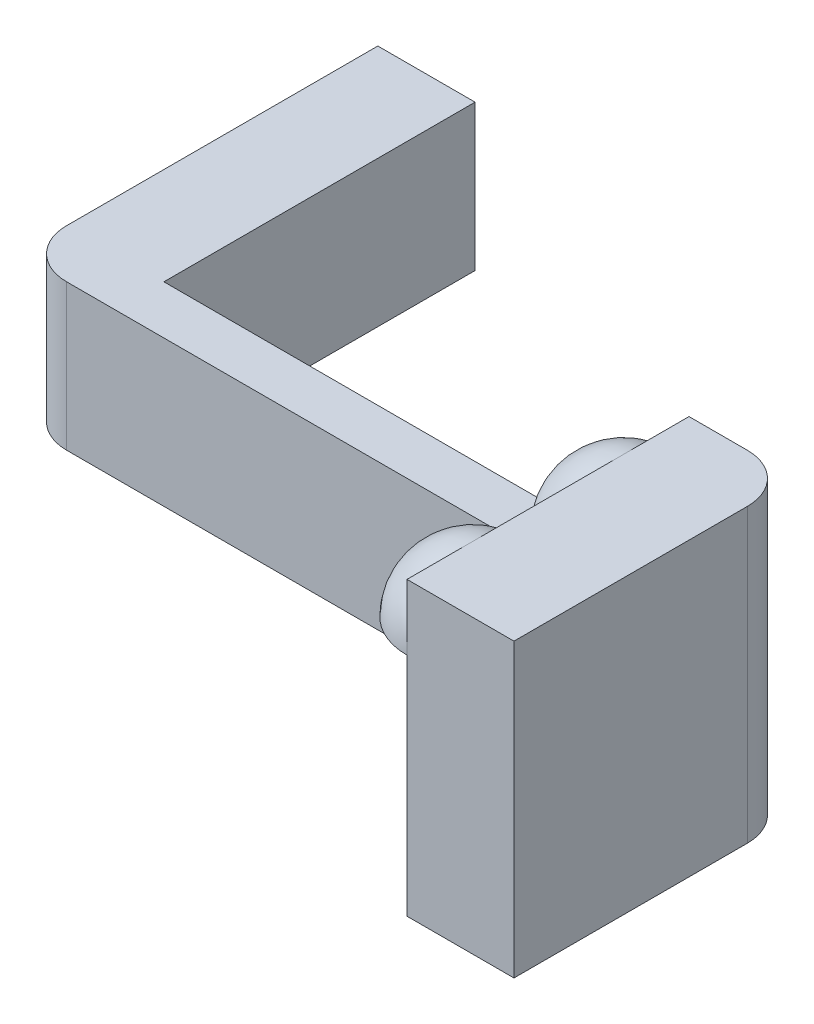
from build123d import *

# Parameters (mm, degrees)
SKETCH1_W                       = 60
SKETCH1_H                       = 15
BOSS_EXTRUDE1_DEPTH             = 5
SKETCH2_W                       = 37
SKETCH2_H                       = 15
BOSS_EXTRUDE2_DEPTH             = 10
FILLET1_R                       = 5
SKETCH3_W                       = 29
SKETCH3_H                       = 30
BOSS_EXTRUDE3_DEPTH             = 5
FILLET2_R                       = 5
BOSS_EXTRUDE6_REACH             = 26
SKETCH8_W                       = 6
SKETCH8_H                       = 30
BOSS_EXTRUDE6_DIRECTION_2_REACH = 39
SKETCH7_W                       = 6
SKETCH7_H                       = 22
CUT_EXTRUDE3_DEPTH              = 11
REVOLVE1_ANGLE                  = 90


with BuildPart() as part:
    # Sketch1 → Boss-Extrude1 (new body)
    with BuildSketch(Plane.XY):
        Rectangle(SKETCH1_W, SKETCH1_H)
    extrude(amount=BOSS_EXTRUDE1_DEPTH)

    # Sketch2 → Boss-Extrude2 (add)
    with BuildSketch(Plane.ZY.offset(30)):
        with Locations((-13.5, 0)):
            Rectangle(SKETCH2_W, SKETCH2_H)
    extrude(amount=BOSS_EXTRUDE2_DEPTH)

    # Fillet1
    fillet1_edges = [part.edges().sort_by_distance(p)[0] for p in [
        (-40, 0, 5),
    ]]
    fillet(fillet1_edges, radius=FILLET1_R)

    # Sketch3 → Boss-Extrude3 (add)
    with BuildSketch(Plane(origin=(30, 0, 0), x_dir=(0, 0, -1), z_dir=(1, 0, 0))):
        with Locations((-14.5, 7.5)):
            Rectangle(SKETCH3_W, SKETCH3_H)
    extrude(amount=BOSS_EXTRUDE3_DEPTH)

    # Fillet2
    fillet2_edges = [part.edges().sort_by_distance(p)[0] for p in [
        (35, 7.5, 0),
    ]]
    fillet(fillet2_edges, radius=FILLET2_R)

    # Boss-Extrude6: up to this face of the body (flat: up to its plane)
    boss_extrude6_end = Plane(part.part.faces().sort_by_distance((32.5, 7.5, 29))[0])
    # Sketch8 → Boss-Extrude6 (add, up to the picked face)
    with BuildSketch(Plane.XY.offset(5), mode=Mode.PRIVATE) as boss_extrude6_sk1:
        with Locations((27, 7.5)):
            Rectangle(SKETCH8_W, SKETCH8_H)
    boss_extrude6_tool1 = split(extrude(boss_extrude6_sk1.sketch, amount=BOSS_EXTRUDE6_REACH, mode=Mode.PRIVATE), bisect_by=boss_extrude6_end, keep=Keep.BOTH, mode=Mode.PRIVATE)
    add(boss_extrude6_tool1.solids().sort_by(Axis((27, 7.5, 5), (0, 0, 1)))[0])

    # Boss-Extrude6 direction 2: up to this face of the body (flat: up to its plane)
    boss_extrude6_direction_2_end = Plane(part.part.faces().sort_by_distance((0, 0, 0))[0])
    # Sketch8 → Boss-Extrude6 direction 2 (add, up to the picked face)
    with BuildSketch(Plane.XY.offset(5), mode=Mode.PRIVATE) as boss_extrude6_direction_2_sk1:
        with Locations((27, 7.5)):
            Rectangle(SKETCH8_W, SKETCH8_H)
    boss_extrude6_direction_2_tool1 = split(extrude(boss_extrude6_direction_2_sk1.sketch, amount=-BOSS_EXTRUDE6_DIRECTION_2_REACH, mode=Mode.PRIVATE), bisect_by=boss_extrude6_direction_2_end, keep=Keep.BOTH, mode=Mode.PRIVATE)
    add(boss_extrude6_direction_2_tool1.solids().sort_by(Axis((27, 7.5, 5), (0, 0, -1)))[0])

    # Sketch7 → Cut-Extrude3 (cut)
    with BuildSketch(Plane.XZ.offset(7.5)):
        with Locations((30, 16)):
            Rectangle(SKETCH7_W, SKETCH7_H)
        with Locations((-35, -16)):
            Rectangle(SKETCH7_W, SKETCH7_H)
    extrude(amount=-CUT_EXTRUDE3_DEPTH, mode=Mode.SUBTRACT)

    # Sketch9 → Revolve1 (revolve)
    with BuildSketch(Plane.ZY.offset(-24)):
        with BuildLine():
            Line((15.5, 15.75), (29, 15.75))
            ThreePointArc((29, 15.75), (22.25, 22.5), (15.5, 15.75))
        make_face()
        with BuildLine():
            ThreePointArc((13.5, 15.75), (6.75, 22.5), (0, 15.75))
            Line((0, 15.75), (13.5, 15.75))
        make_face()
    revolve(axis=Axis((24, 15.75, 0), (0, 0, 1)), revolution_arc=REVOLVE1_ANGLE)


solid = part.part
